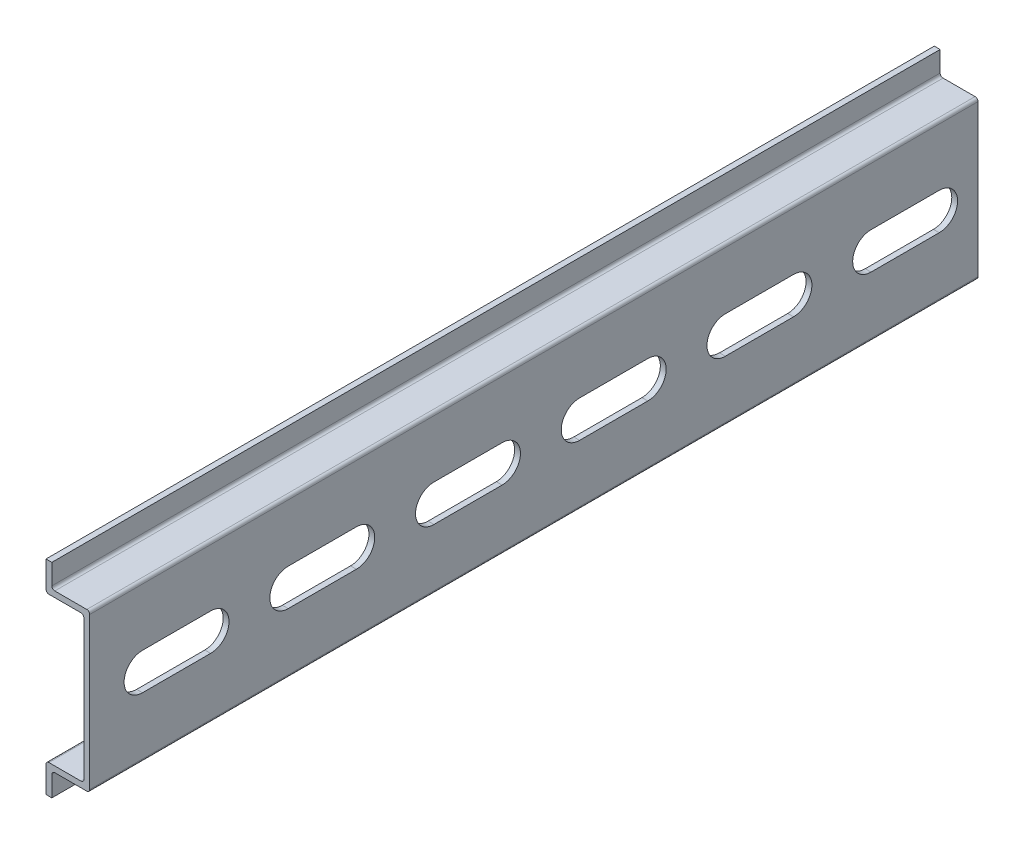
from build123d import *

# Parameters (mm, degrees)
EXTRUDE_THIN1_DEPTH = 449.2625
CUT_EXTRUDE1_START  = -8.5
CUT_EXTRUDE1_DEPTH  = 9.5
LPATTERN1_COUNT     = 18
LPATTERN1_PITCH     = 25
FILLET1_R           = 0.5
SKETCH5_W           = 23.532863881
SKETCH5_H           = 44.509442227
CUT_EXTRUDE2_DEPTH  = 296.8625


with BuildPart() as part:
    # Sketch3 → Extrude-Thin1 (new body)
    with BuildSketch(Plane.XY):
        Polygon((-6.5, 17.5), (-6.5, 13.5), (0, 13.5), (0, -13.5), (-6.5, -13.5), (-6.5, -17.5), (-7.5, -17.5), (-7.5, -12.5), (-1, -12.5), (-1, 12.5), (-7.5, 12.5), (-7.5, 17.5), align=None)
    extrude(amount=EXTRUDE_THIN1_DEPTH)

    # Sketch4 → Cut-Extrude1 (cut)
    with BuildSketch(Plane(origin=(0, 0, 0), x_dir=(0, 0, -1), z_dir=(1, 0, 0)).offset(CUT_EXTRUDE1_START)):
        with BuildLine():
            Line((-6.65, -3.15), (-18.35, -3.15))
            ThreePointArc((-18.35, -3.15), (-21.5, 0), (-18.35, 3.15))
            Line((-18.35, 3.15), (-6.65, 3.15))
            ThreePointArc((-6.65, 3.15), (-3.5, 0), (-6.65, -3.15))
        make_face()
    cut_extrude1 = extrude(amount=CUT_EXTRUDE1_DEPTH, mode=Mode.SUBTRACT)

    # LPattern1: Cut-Extrude1 ×18
    with Locations(*[(0, 0, i * LPATTERN1_PITCH) for i in range(1, LPATTERN1_COUNT)]):
        add(cut_extrude1, mode=Mode.SUBTRACT)

    # Fillet1
    fillet1_edges = [part.edges().sort_by_distance(p)[0] for p in [
        (-6.5, 13.5, 224.63125),
        (0, 13.5, 224.63125),
        (0, -13.5, 224.63125),
        (-6.5, -13.5, 224.63125),
        (-7.5, -12.5, 224.63125),
        (-1, -12.5, 224.63125),
        (-1, 12.5, 224.63125),
        (-7.5, 12.5, 224.63125),
    ]]
    fillet(fillet1_edges, radius=FILLET1_R)

    # Sketch5 → Cut-Extrude2 (cut)
    with BuildSketch(Plane.XY.offset(449.2625)):
        with Locations((-4.42532449, -0.836961712)):
            Rectangle(SKETCH5_W, SKETCH5_H)
    extrude(amount=-CUT_EXTRUDE2_DEPTH, mode=Mode.SUBTRACT)


solid = part.part
